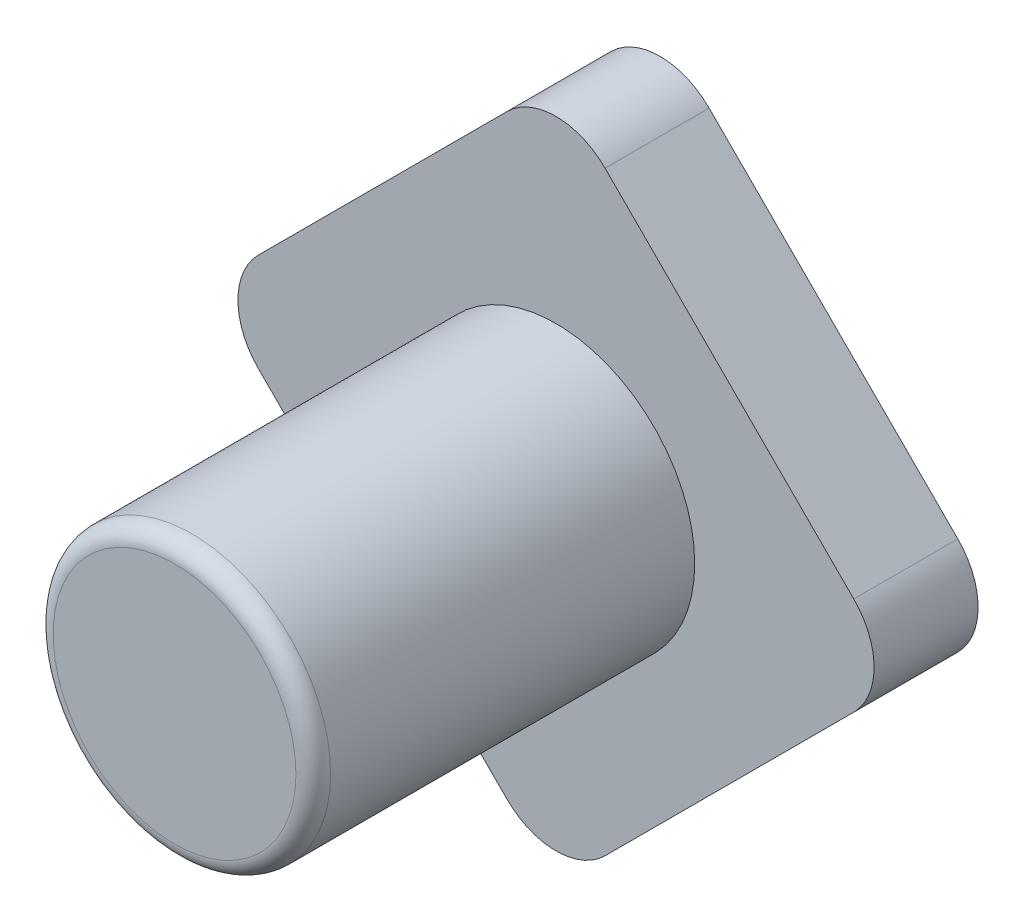
from build123d import *

# Parameters (mm, degrees)
BOSS_EXTRUDE1_DEPTH = 3
SKETCH2_R           = 4
BOSS_EXTRUDE2_DEPTH = 11
FILLET1_R           = 2
FILLET2_R           = 0.5


with BuildPart() as part:
    # Sketch1 → Boss-Extrude1 (new body)
    with BuildSketch(Plane.XY):
        Polygon((0, 10), (10, 0), (0, -10), (-10, 0), align=None)
    extrude(amount=-BOSS_EXTRUDE1_DEPTH)

    # Sketch2 → Boss-Extrude2 (add)
    with BuildSketch(Plane.XY):
        Circle(SKETCH2_R)
    extrude(amount=BOSS_EXTRUDE2_DEPTH)

    # Fillet1
    fillet1_edges = [part.edges().sort_by_distance(p)[0] for p in [
        (0, 10, -1.5),
        (10, 0, -1.5),
        (0, -10, -1.5),
        (-10, 0, -1.5),
    ]]
    fillet(fillet1_edges, radius=FILLET1_R)

    # Fillet2
    fillet2_edges = [part.edges().sort_by_distance(p)[0] for p in [
        (-4, 0, 11),
    ]]
    fillet(fillet2_edges, radius=FILLET2_R)


solid = part.part
